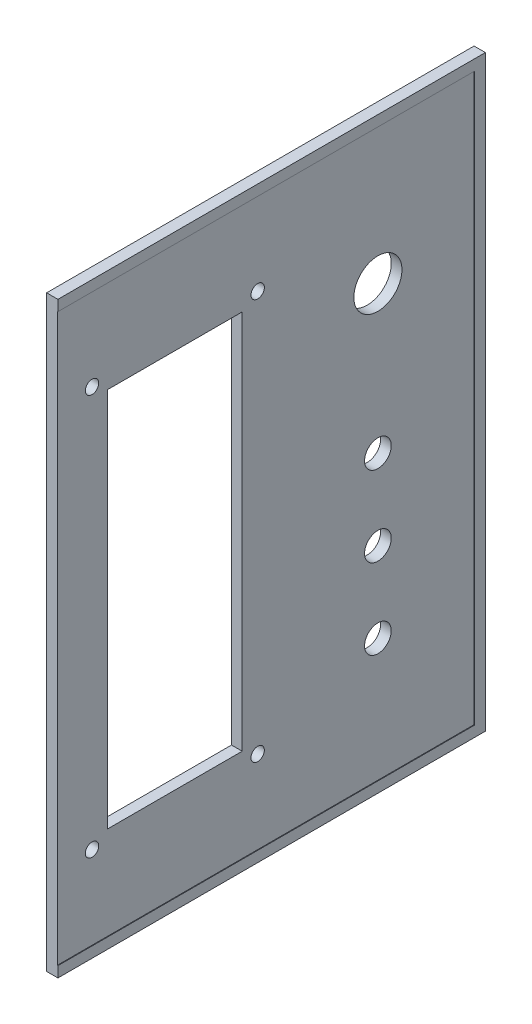
from build123d import *

# Parameters (mm, degrees)
SKETCH1_W           = 155
SKETCH1_H           = 110
BOSS_EXTRUDE1_DEPTH = 80
SKETCH2_W           = 151
SKETCH2_H           = 106
CUT_EXTRUDE1_DEPTH  = 78
SKETCH3_R           = 2.5
CUT_EXTRUDE2_DEPTH  = 2
SKETCH7_R           = 1.6
CUT_EXTRUDE7_DEPTH  = 2
SKETCH4_W           = 27.5
SKETCH4_H           = 46.8
CUT_EXTRUDE8_DEPTH  = 2
SKETCH8_W           = 4
SKETCH8_H           = 53
CUT_EXTRUDE9_DEPTH  = 2
SKETCH9_W           = 14
SKETCH9_H           = 14
CUT_EXTRUDE10_DEPTH = 2
SKETCH10_W          = 25.2
SKETCH10_H          = 71.2
SKETCH10_R          = 1.25
CUT_EXTRUDE12_DEPTH = 2
SKETCH11_R          = 2.5
SKETCH11_R_2        = 4.5
CUT_EXTRUDE13_DEPTH = 2
SKETCH12_W          = 152.88518354
SKETCH12_H          = 110
CUT_EXTRUDE14_DEPTH = 80


with BuildPart() as part:
    # Sketch1 → Boss-Extrude1 (new body)
    with BuildSketch(Plane.XY):
        with Locations((77.5, 55)):
            Rectangle(SKETCH1_W, SKETCH1_H)
    extrude(amount=BOSS_EXTRUDE1_DEPTH)

    # Sketch2 → Cut-Extrude1 (cut)
    with BuildSketch(Plane.XY.offset(80)):
        with Locations((77.5, 55)):
            Rectangle(SKETCH2_W, SKETCH2_H)
    extrude(amount=-CUT_EXTRUDE1_DEPTH, mode=Mode.SUBTRACT)

    # Sketch3 → Cut-Extrude2 (cut)
    with BuildSketch(Plane.XY.offset(2)):
        with Locations((145, 100.5)):
            Circle(SKETCH3_R)
        with Locations((145, 9.5)):
            Circle(SKETCH3_R)
        with Locations((10, 9.5)):
            Circle(SKETCH3_R)
        with Locations((10, 100.5)):
            Circle(SKETCH3_R)
    extrude(amount=-CUT_EXTRUDE2_DEPTH, mode=Mode.SUBTRACT)

    # Sketch7 → Cut-Extrude7 (cut)
    with BuildSketch(Plane(origin=(0, 110, 0), x_dir=(1, 0, 0), z_dir=(0, 1, 0))):
        with Locations((44.48, -20.14450396)):
            Circle(SKETCH7_R)
        with Locations((95.28, -17.14)):
            Circle(SKETCH7_R)
        with Locations((95.28, -62.86)):
            Circle(SKETCH7_R)
        with Locations((44.48, -47.62)):
            Circle(SKETCH7_R)
    extrude(amount=-CUT_EXTRUDE7_DEPTH, mode=Mode.SUBTRACT)

    # Sketch4 → Cut-Extrude8 (cut)
    with BuildSketch(Plane(origin=(155, 0, 0), x_dir=(0, 0, -1), z_dir=(1, 0, 0))):
        with Locations((-40, 82.5)):
            Rectangle(SKETCH4_W, SKETCH4_H)
    extrude(amount=-CUT_EXTRUDE8_DEPTH, mode=Mode.SUBTRACT)

    # Sketch8 → Cut-Extrude9 (cut)
    with BuildSketch(Plane(origin=(155, 0, 0), x_dir=(0, 0, -1), z_dir=(1, 0, 0))):
        with Locations((-68, 28.5)):
            Rectangle(SKETCH8_W, SKETCH8_H)
        with Locations((-76, 28.5)):
            Rectangle(SKETCH8_W, SKETCH8_H)
        with Locations((-60, 28.5)):
            Rectangle(SKETCH8_W, SKETCH8_H)
        with Locations((-52, 28.5)):
            Rectangle(SKETCH8_W, SKETCH8_H)
        with Locations((-44, 28.5)):
            Rectangle(SKETCH8_W, SKETCH8_H)
        with Locations((-36, 28.5)):
            Rectangle(SKETCH8_W, SKETCH8_H)
        with Locations((-28, 28.5)):
            Rectangle(SKETCH8_W, SKETCH8_H)
        with Locations((-20, 28.5)):
            Rectangle(SKETCH8_W, SKETCH8_H)
        with Locations((-12, 28.5)):
            Rectangle(SKETCH8_W, SKETCH8_H)
        with Locations((-4, 28.5)):
            Rectangle(SKETCH8_W, SKETCH8_H)
    extrude(amount=-CUT_EXTRUDE9_DEPTH, mode=Mode.SUBTRACT)

    # Sketch9 → Cut-Extrude10 (cut)
    with BuildSketch(Plane(origin=(0, 110, 0), x_dir=(1, 0, 0), z_dir=(0, 1, 0))):
        with Locations((120, -19)):
            Rectangle(SKETCH9_W, SKETCH9_H)
    extrude(amount=-CUT_EXTRUDE10_DEPTH, mode=Mode.SUBTRACT)

    # Sketch10 → Cut-Extrude12 (cut)
    with BuildSketch(Plane.ZY):
        with Locations((58, 55)):
            Rectangle(SKETCH10_W, SKETCH10_H)
        with Locations((42.5, 92.5)):
            Circle(SKETCH10_R)
        with Locations((73.5, 92.5)):
            Circle(SKETCH10_R)
        with Locations((42.5, 17.5)):
            Circle(SKETCH10_R)
        with Locations((73.5, 17.5)):
            Circle(SKETCH10_R)
    extrude(amount=-CUT_EXTRUDE12_DEPTH, mode=Mode.SUBTRACT)

    # Sketch11 → Cut-Extrude13 (cut)
    with BuildSketch(Plane.ZY):
        with Locations((20, 55)):
            Circle(SKETCH11_R)
        with Locations((20, 40)):
            Circle(SKETCH11_R)
        with Locations((20, 25)):
            Circle(SKETCH11_R)
        with Locations((20, 82.5)):
            Circle(SKETCH11_R_2)
    extrude(amount=-CUT_EXTRUDE13_DEPTH, mode=Mode.SUBTRACT)

    # Sketch12 → Cut-Extrude14 (cut)
    with BuildSketch(Plane.XY.offset(80)):
        with Locations((78.55740823, 55)):
            Rectangle(SKETCH12_W, SKETCH12_H)
    extrude(amount=-CUT_EXTRUDE14_DEPTH, mode=Mode.SUBTRACT)


solid = part.part
